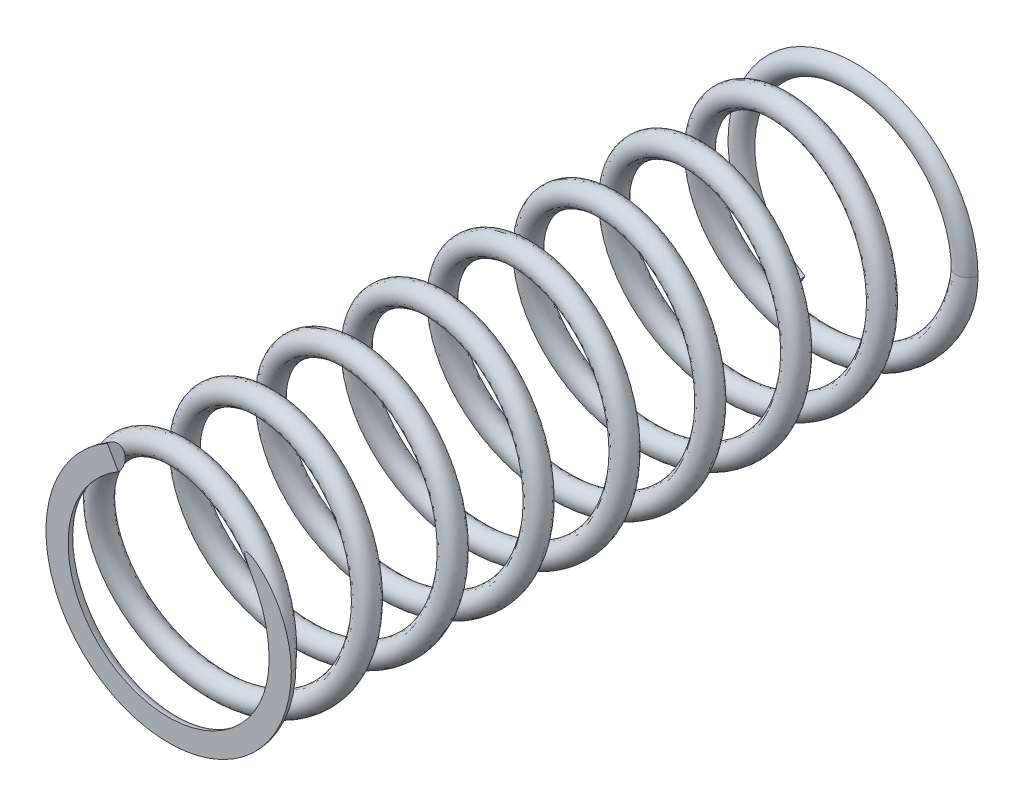
from build123d import *

# Parameters (mm, degrees)
SWEEP1_PITCH       = 15.5
SWEEP1_HEIGHT      = 124
SWEEP1_RADIUS      = 20.15
SWEEP1_PROFILE_R   = 2
SWEEP2_PROFILE_R   = 2
SKETCH41_R         = 25
CUT_EXTRUDE1_DEPTH = 3.0000001
SWEEP3_PROFILE_R   = 2
SKETCH55_R         = 25
CUT_EXTRUDE2_DEPTH = 3.0000001


with BuildPart() as part:
    # Sweep1: sweep along a helix
    with BuildLine() as sweep1_path:
        Helix(SWEEP1_PITCH, SWEEP1_HEIGHT, SWEEP1_RADIUS, center=(0, 0, 0), direction=(0, 0, 1), lefthand=True)
    # Sweep1 profile (on start of the path) → Sweep1 (sweep)
    with BuildSketch(Plane(origin=(20.15, 0, 0), x_dir=(0, -0.121519578, -0.992589035), z_dir=(0, -0.992589035, 0.121519578))):
        Circle(SWEEP1_PROFILE_R)
    sweep(path=sweep1_path.line, is_frenet=True)

    # Sweep2: sweep along a path in Sketch10
    with BuildLine(Plane.XY.offset(124)) as sweep2_path:
        ThreePointArc((20.15, 0), (-10.075, -17.450411886), (-10.075, 17.450411886))
    # Sweep2 profile (on start of the path) → Sweep2 (sweep)
    with BuildSketch(Plane(origin=(20.15, 0, 124), x_dir=(-1, 0, 0), z_dir=(0, -1, 0))):
        Circle(SWEEP2_PROFILE_R)
    sweep(path=sweep2_path.line)

    # Sketch41 → Cut-Extrude1 (cut, through all)
    with BuildSketch(Plane.XY.offset(124)):
        Circle(SKETCH41_R)
    extrude(amount=CUT_EXTRUDE1_DEPTH, mode=Mode.SUBTRACT)

    # Sweep3: sweep along a path in Sketch42
    with BuildLine(Plane.XY) as sweep3_path:
        ThreePointArc((20.15, 0), (-10.075, 17.450411886), (-10.075, -17.450411886))
    # Sweep3 profile (on start of the path) → Sweep3 (sweep)
    with BuildSketch(Plane(origin=(20.15, 0, 0), x_dir=(1, 0, 0), z_dir=(0, 1, 0))):
        Circle(SWEEP3_PROFILE_R)
    sweep(path=sweep3_path.line)

    # Sketch55 → Cut-Extrude2 (cut, through all)
    with BuildSketch(Plane.XY):
        Circle(SKETCH55_R)
    extrude(amount=-CUT_EXTRUDE2_DEPTH, mode=Mode.SUBTRACT)


solid = part.part
